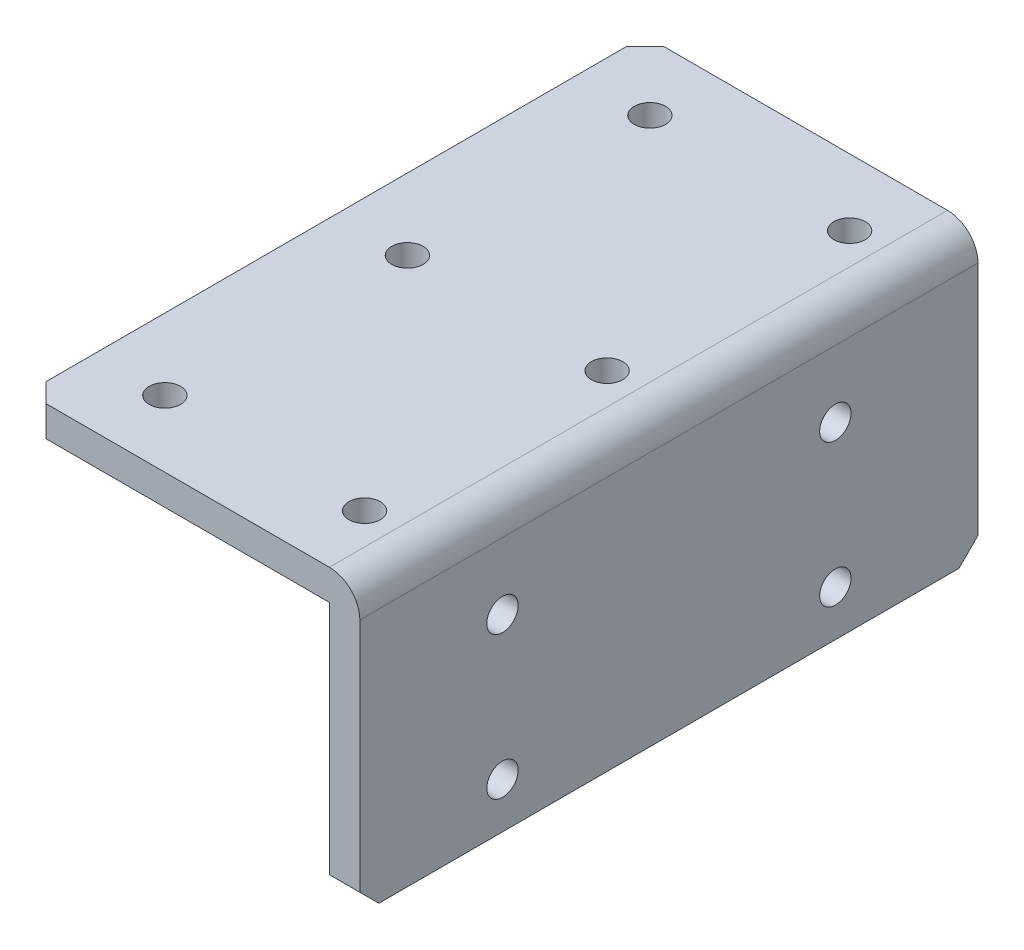
from build123d import *

# Parameters (mm, degrees)
BOSS_EXTRUDE1_DEPTH       = 32.5
BOSS_EXTRUDE1_DEPTH_BACK  = 32.5
FILLET1_R                 = 3.2
M4X0_7_TAPPED_HOLE1_D     = 3.3
M4X0_7_TAPPED_HOLE1_DEPTH = 3.2
M4X0_7_TAPPED_HOLE2_D     = 3.3
M4X0_7_TAPPED_HOLE2_DEPTH = 3.2
LPATTERN1_COUNT           = 2
LPATTERN1_PITCH           = 21
LPATTERN1_COUNT_DIR2      = 3
LPATTERN1_PITCH_DIR2      = 25.5
CHAMFER1_SIZE             = 2


with BuildPart() as part:
    # Sketch1 → Boss-Extrude1 (new body, two sides)
    with BuildSketch(Plane.XY) as boss_extrude1_sk:
        Polygon((0, -30), (-3.2, -30), (-3.2, -3.2), (-35, -3.2), (-35, 0), (0, 0), align=None)
    extrude(amount=BOSS_EXTRUDE1_DEPTH)
    extrude(boss_extrude1_sk.sketch, amount=-BOSS_EXTRUDE1_DEPTH_BACK)

    # Fillet1
    fillet1_edges = [part.edges().sort_by_distance(p)[0] for p in [
        (0, 0, 0),
    ]]
    fillet(fillet1_edges, radius=FILLET1_R)

    # M4x0.7 Tapped Hole1
    with Locations(Plane(origin=(0, 0, 0), x_dir=(0, 0, -1), z_dir=(1, 0, 0))):
        with Locations((-17.5, -10.2), (-17.5, -25.2), (17.5, -25.2), (17.5, -10.2)):
            Hole(M4X0_7_TAPPED_HOLE1_D / 2, depth=M4X0_7_TAPPED_HOLE1_DEPTH)

    # M4x0.7 Tapped Hole2
    with Locations(Plane(origin=(0, 0, 0), x_dir=(-1, 0, 0), z_dir=(0, 1, 0))):
        with Locations((6.5, 25.5)):
            m4x0_7_tapped_hole2 = Hole(M4X0_7_TAPPED_HOLE2_D / 2, depth=M4X0_7_TAPPED_HOLE2_DEPTH)

    # LPattern1: M4x0.7 Tapped Hole2 2 × 3
    with Locations(*[(-i * LPATTERN1_PITCH, 0, -j * LPATTERN1_PITCH_DIR2) for i in range(LPATTERN1_COUNT) for j in range(LPATTERN1_COUNT_DIR2) if (i, j) != (0, 0)]):
        add(m4x0_7_tapped_hole2, mode=Mode.SUBTRACT)

    # Chamfer1
    chamfer1_edges = [part.edges().sort_by_distance(p)[0] for p in [
        (-35, -1.6, -32.5),
        (-35, -1.6, 32.5),
        (-1.6, -30, -32.5),
        (-1.6, -30, 32.5),
    ]]
    chamfer(chamfer1_edges, length=CHAMFER1_SIZE)


solid = part.part
